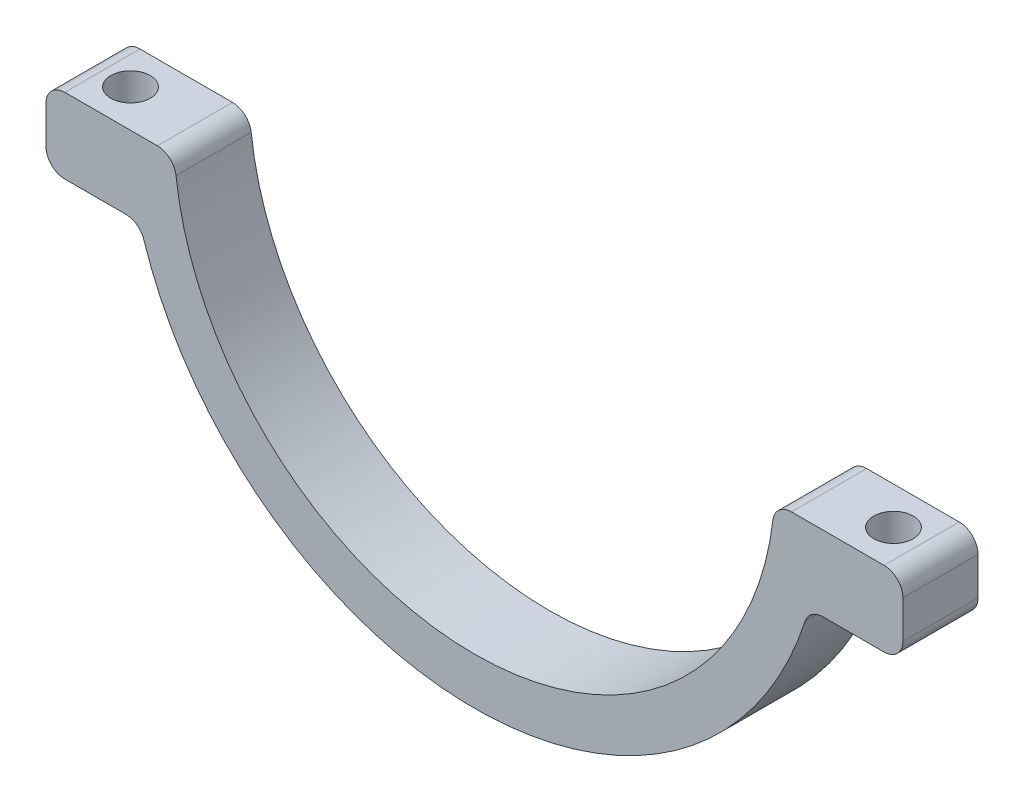
from build123d import *

# Parameters (mm, degrees)
BOSS_EXTRUDE1_DEPTH = 8
SKETCH5_R           = 2.1
CUT_EXTRUDE1_DEPTH  = 5
SKETCH6_R           = 1.65
CUT_EXTRUDE2_DEPTH  = 36
FILLET1_R           = 2


with BuildPart() as part:
    # Sketch3 → Boss-Extrude1 (new body)
    with BuildSketch(Plane.XY):
        with BuildLine():
            Line((-31.937438845, -2), (-45.623026261, -2))
            Line((-45.623026261, -2), (-45.623026261, -10))
            Line((-45.623026261, -10), (-35.623026261, -10))
            ThreePointArc((-35.623026261, -10), (0, -37), (35.623026261, -10))
            Line((35.623026261, -10), (45.623026261, -10))
            Line((45.623026261, -10), (45.623026261, -2))
            Line((45.623026261, -2), (31.937438845, -2))
            ThreePointArc((31.937438845, -2), (0, -32), (-31.937438845, -2))
        make_face()
    extrude(amount=BOSS_EXTRUDE1_DEPTH)

    # Sketch5 → Cut-Extrude1 (cut)
    with BuildSketch(Plane.XZ.offset(2)):
        with Locations((40.623026261, 4)):
            Circle(SKETCH5_R)
    cut_extrude1 = extrude(amount=CUT_EXTRUDE1_DEPTH, mode=Mode.SUBTRACT)

    # Sketch6 → Cut-Extrude2 (cut, through all)
    with BuildSketch(Plane(origin=(0, -2, 0), x_dir=(1, 0, 0), z_dir=(0, 1, 0))):
        with Locations((40.623026261, -4)):
            Circle(SKETCH6_R)
    cut_extrude2 = extrude(amount=-CUT_EXTRUDE2_DEPTH, mode=Mode.SUBTRACT)

    # Mirror1: Cut-Extrude1, Cut-Extrude2 across plane
    add(cut_extrude1.mirror(Plane(origin=(0, 0, 0), x_dir=(0, 0, 1), z_dir=(1, 0, 0))), mode=Mode.SUBTRACT)
    add(cut_extrude2.mirror(Plane(origin=(0, 0, 0), x_dir=(0, 0, 1), z_dir=(1, 0, 0))), mode=Mode.SUBTRACT)

    # Fillet1
    fillet1_edges = [part.edges().sort_by_distance(p)[0] for p in [
        (-45.623026261, -2, 4),
        (-31.937438845, -2, 4),
        (31.937438845, -2, 4),
        (45.623026261, -2, 4),
        (45.623026261, -10, 4),
        (35.623026261, -10, 4),
        (-35.623026261, -10, 4),
        (-45.623026261, -10, 4),
    ]]
    fillet(fillet1_edges, radius=FILLET1_R)


solid = part.part
